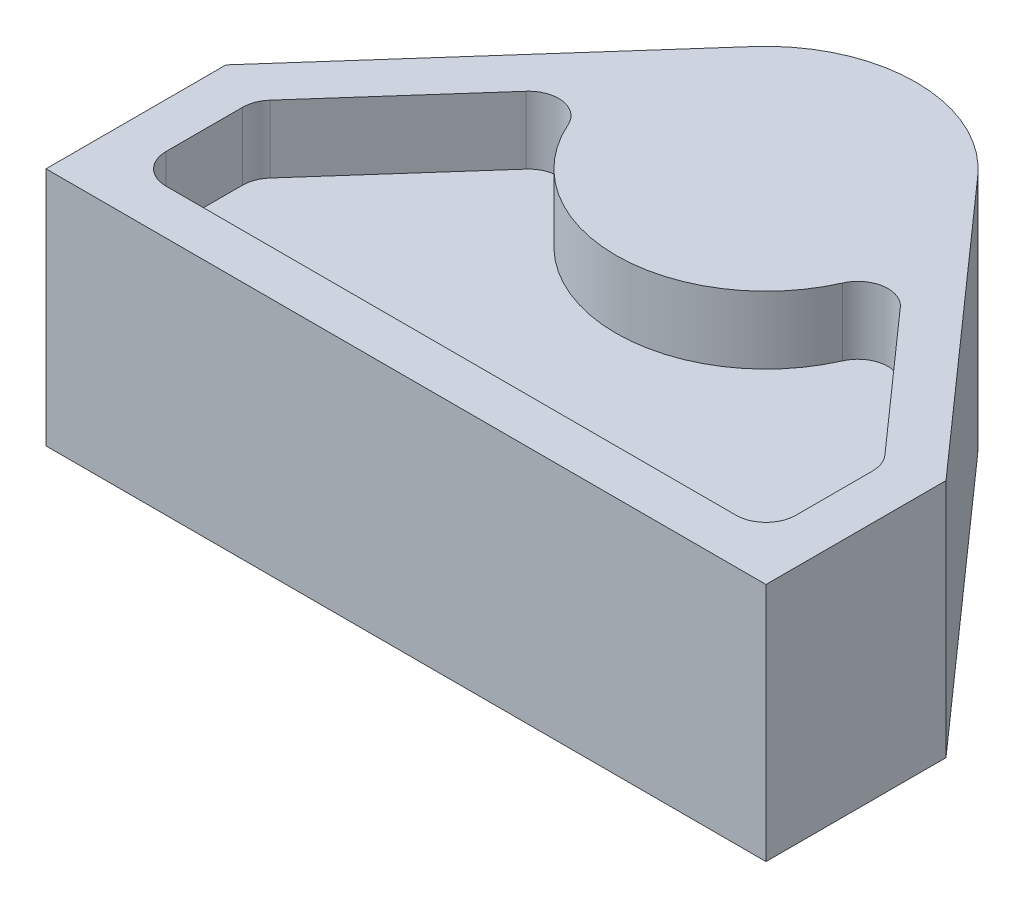
from build123d import *

# Parameters (mm, degrees)
SKETCH1_W           = 76.2
SKETCH1_H           = 19.05
BOSS_EXTRUDE1_DEPTH = 25.4
BOSS_EXTRUDE2_DEPTH = 25.4
CUT_EXTRUDE1_DEPTH  = 7.1374


with BuildPart() as part:
    # Sketch1 → Boss-Extrude1 (new body)
    with BuildSketch(Plane(origin=(0, 0, 0), x_dir=(1, 0, 0), z_dir=(0, 1, 0))):
        Rectangle(SKETCH1_W, SKETCH1_H)
    extrude(amount=BOSS_EXTRUDE1_DEPTH)

    # Sketch2 → Boss-Extrude2 (add)
    with BuildSketch(Plane(origin=(0, 0, 0), x_dir=(1, 0, 0), z_dir=(0, 1, 0))):
        with BuildLine():
            Line((-38.1, 9.525), (-11.879738537, 39.105310408))
            ThreePointArc((-11.879738537, 39.105310408), (0, 44.45), (11.879738537, 39.105310408))
            Line((11.879738537, 39.105310408), (38.1, 9.525))
            Line((38.1, 9.525), (38.1, -9.525))
            Line((38.1, -9.525), (-38.1, -9.525))
            Line((-38.1, -9.525), (-38.1, 9.525))
        make_face()
    extrude(amount=BOSS_EXTRUDE2_DEPTH)

    # Sketch3 → Cut-Extrude1 (cut)
    with BuildSketch(Plane(origin=(0, 25.4, 0), x_dir=(1, 0, 0), z_dir=(0, 1, 0))):
        with BuildLine():
            Line((-30.1625, -4.7625), (30.1625, -4.7625))
            ThreePointArc((30.1625, -4.7625), (32.40756403, -3.83256403), (33.3375, -1.5875))
            Line((33.3375, -1.5875), (33.3375, 6.513465997))
            ThreePointArc((33.3375, 6.513465997), (33.131023115, 7.639741058), (32.538447707, 8.619528078))
            Line((32.538447707, 8.619528078), (19.803029448, 22.986952515))
            ThreePointArc((19.803029448, 22.986952515), (16.937724791, 24.017951921), (14.522568117, 22.163242028))
            ThreePointArc((14.522568117, 22.163242028), (0, 12.7), (-14.522568117, 22.163242028))
            ThreePointArc((-14.522568117, 22.163242028), (-16.937724791, 24.017951921), (-19.803029448, 22.986952515))
            Line((-19.803029448, 22.986952515), (-32.538447707, 8.619528078))
            ThreePointArc((-32.538447707, 8.619528078), (-33.131023115, 7.639741058), (-33.3375, 6.513465997))
            Line((-33.3375, 6.513465997), (-33.3375, -1.5875))
            ThreePointArc((-33.3375, -1.5875), (-32.40756403, -3.83256403), (-30.1625, -4.7625))
        make_face()
    extrude(amount=-CUT_EXTRUDE1_DEPTH, mode=Mode.SUBTRACT)


solid = part.part
